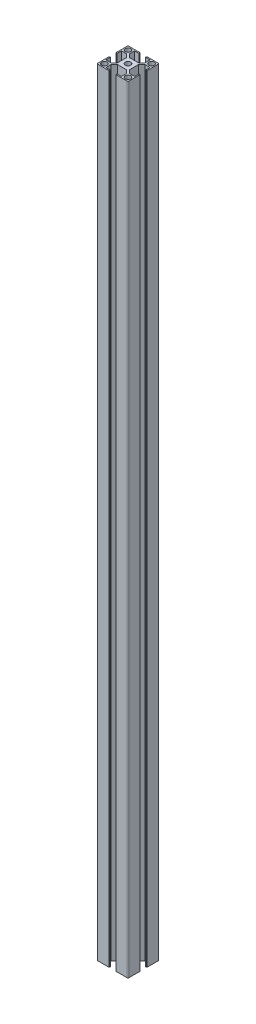
from build123d import *

# Parameters (mm, degrees)
SKETCH1_R           = 3.5
BOSS_EXTRUDE1_DEPTH = 1000
CUT_EXTRUDE1_DEPTH  = 1001


with BuildPart() as part:
    # Sketch1 → Boss-Extrude1 (new body)
    with BuildSketch(Plane(origin=(0, 0, 0), x_dir=(1, 0, 0), z_dir=(0, 1, 0))):
        with BuildLine():
            Line((20, 19), (20, -19))
            ThreePointArc((20, -19), (19.707106781, -19.707106781), (19, -20))
            Line((19, -20), (-19, -20))
            ThreePointArc((-19, -20), (-19.707106781, -19.707106781), (-20, -19))
            Line((-20, -19), (-20, 19))
            ThreePointArc((-20, 19), (-19.707106781, 19.707106781), (-19, 20))
            Line((-19, 20), (19, 20))
            ThreePointArc((19, 20), (19.707106781, 19.707106781), (20, 19))
        make_face()
        with Locations((15.1625, -15.1625)):
            Circle(SKETCH1_R, mode=Mode.SUBTRACT)
        with Locations((-15.1625, -15.1625)):
            Circle(SKETCH1_R, mode=Mode.SUBTRACT)
        with Locations((-15.1625, 15.1625)):
            Circle(SKETCH1_R, mode=Mode.SUBTRACT)
        with Locations((15.1625, 15.1625)):
            Circle(SKETCH1_R, mode=Mode.SUBTRACT)
        Circle(SKETCH1_R, mode=Mode.SUBTRACT)
        Polygon((-10, -18.5), (10, -18.5), (10, -11.825), (5.875, -7.7), (-5.875, -7.7), (-10, -11.825), align=None, mode=Mode.SUBTRACT)
        Polygon((-11.825, -10), (-18.5, -10), (-18.5, 10), (-11.825, 10), (-7.7, 5.875), (-7.7, -5.875), align=None, mode=Mode.SUBTRACT)
        Polygon((-10, 11.825), (-10, 18.5), (10, 18.5), (10, 11.825), (5.875, 7.7), (-5.875, 7.7), align=None, mode=Mode.SUBTRACT)
        Polygon((18.5, -10), (18.5, 10), (11.825, 10), (7.7, 5.875), (7.7, -5.875), (11.825, -10), align=None, mode=Mode.SUBTRACT)
    extrude(amount=BOSS_EXTRUDE1_DEPTH)

    # Sketch2 → Cut-Extrude1 (cut, through all)
    with BuildSketch(Plane(origin=(0, 1000, 0), x_dir=(1, 0, 0), z_dir=(0, 1, 0))):
        with BuildLine():
            Line((-4.65, 20), (-4.65, 19.35))
            ThreePointArc((-4.65, 19.35), (-4.620710678, 19.279289322), (-4.55, 19.25))
            Line((-4.55, 19.25), (-4.25, 19.25))
            ThreePointArc((-4.25, 19.25), (-4.179289322, 19.220710678), (-4.15, 19.15))
            Line((-4.15, 19.15), (-4.15, 18.5))
            Line((-4.15, 18.5), (4.15, 18.5))
            Line((4.15, 18.5), (4.15, 19.15))
            ThreePointArc((4.15, 19.15), (4.179289322, 19.220710678), (4.25, 19.25))
            Line((4.25, 19.25), (4.55, 19.25))
            ThreePointArc((4.55, 19.25), (4.620710678, 19.279289322), (4.65, 19.35))
            Line((4.65, 19.35), (4.65, 20))
            Line((4.65, 20), (-4.65, 20))
        make_face()
        with BuildLine():
            Line((20, 4.65), (19.35, 4.65))
            ThreePointArc((19.35, 4.65), (19.279289322, 4.620710678), (19.25, 4.55))
            Line((19.25, 4.55), (19.25, 4.25))
            ThreePointArc((19.25, 4.25), (19.220710678, 4.179289322), (19.15, 4.15))
            Line((19.15, 4.15), (18.5, 4.15))
            Line((18.5, 4.15), (18.5, -4.15))
            Line((18.5, -4.15), (19.15, -4.15))
            ThreePointArc((19.15, -4.15), (19.220710678, -4.179289322), (19.25, -4.25))
            Line((19.25, -4.25), (19.25, -4.55))
            ThreePointArc((19.25, -4.55), (19.279289322, -4.620710678), (19.35, -4.65))
            Line((19.35, -4.65), (20, -4.65))
            Line((20, -4.65), (20, 4.65))
        make_face()
        with BuildLine():
            Line((4.65, -20), (4.65, -19.35))
            ThreePointArc((4.65, -19.35), (4.620710678, -19.279289322), (4.55, -19.25))
            Line((4.55, -19.25), (4.25, -19.25))
            ThreePointArc((4.25, -19.25), (4.179289322, -19.220710678), (4.15, -19.15))
            Line((4.15, -19.15), (4.15, -18.5))
            Line((4.15, -18.5), (-4.15, -18.5))
            Line((-4.15, -18.5), (-4.15, -19.15))
            ThreePointArc((-4.15, -19.15), (-4.179289322, -19.220710678), (-4.25, -19.25))
            Line((-4.25, -19.25), (-4.55, -19.25))
            ThreePointArc((-4.55, -19.25), (-4.620710678, -19.279289322), (-4.65, -19.35))
            Line((-4.65, -19.35), (-4.65, -20))
            Line((-4.65, -20), (4.65, -20))
        make_face()
        with BuildLine():
            Line((-20, -4.65), (-19.35, -4.65))
            ThreePointArc((-19.35, -4.65), (-19.279289322, -4.620710678), (-19.25, -4.55))
            Line((-19.25, -4.55), (-19.25, -4.25))
            ThreePointArc((-19.25, -4.25), (-19.220710678, -4.179289322), (-19.15, -4.15))
            Line((-19.15, -4.15), (-18.5, -4.15))
            Line((-18.5, -4.15), (-18.5, 4.15))
            Line((-18.5, 4.15), (-19.15, 4.15))
            ThreePointArc((-19.15, 4.15), (-19.220710678, 4.179289322), (-19.25, 4.25))
            Line((-19.25, 4.25), (-19.25, 4.55))
            ThreePointArc((-19.25, 4.55), (-19.279289322, 4.620710678), (-19.35, 4.65))
            Line((-19.35, 4.65), (-20, 4.65))
            Line((-20, 4.65), (-20, -4.65))
        make_face()
    extrude(amount=-CUT_EXTRUDE1_DEPTH, mode=Mode.SUBTRACT)


solid = part.part
